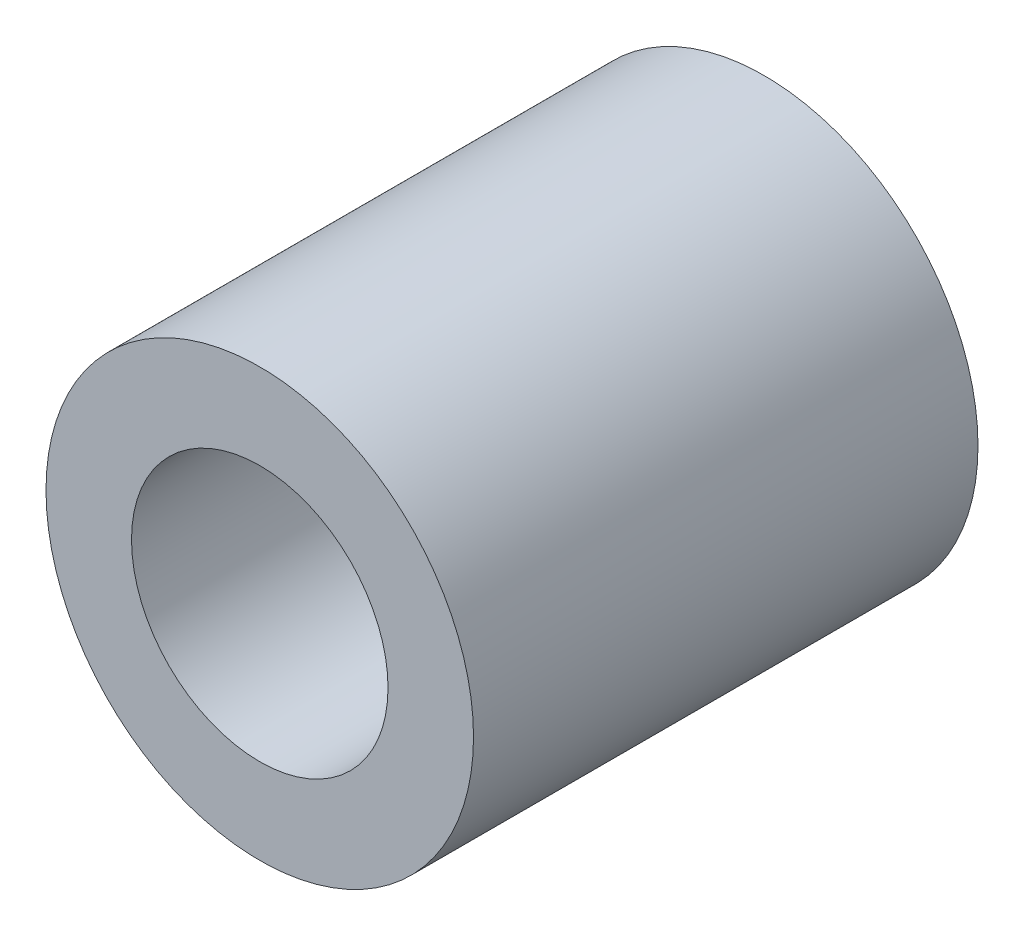
from build123d import *

# Parameters (mm, degrees)
SKETCH2_R           = 2.5
SKETCH2_R_2         = 1.5
BOSS_EXTRUDE1_DEPTH = 5.9


with BuildPart() as part:
    # Sketch2 → Boss-Extrude1 (new body)
    with BuildSketch(Plane.XY):
        Circle(SKETCH2_R)
        Circle(SKETCH2_R_2, mode=Mode.SUBTRACT)
    extrude(amount=BOSS_EXTRUDE1_DEPTH)


solid = part.part
